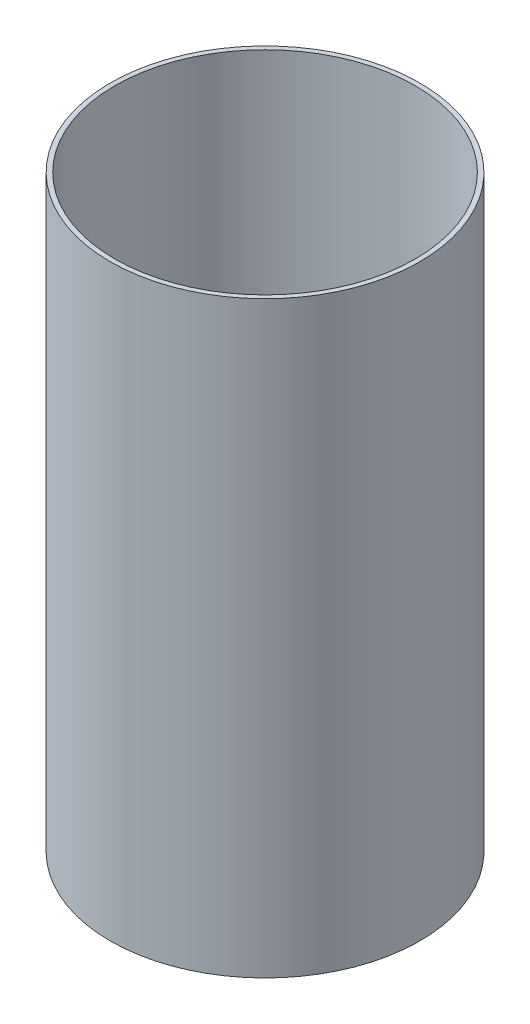
from build123d import *

# Parameters (mm, degrees)
SKETCH1_R           = 63.5
SKETCH1_R_2         = 61.595
BOSS_EXTRUDE1_DEPTH = 120.65


with BuildPart() as part:
    # Sketch1 → Boss-Extrude1 (new body, symmetric)
    with BuildSketch(Plane(origin=(0, 0, 0), x_dir=(1, 0, 0), z_dir=(0, 1, 0))):
        Circle(SKETCH1_R)
        Circle(SKETCH1_R_2, mode=Mode.SUBTRACT)
    extrude(amount=BOSS_EXTRUDE1_DEPTH, both=True)


solid = part.part
